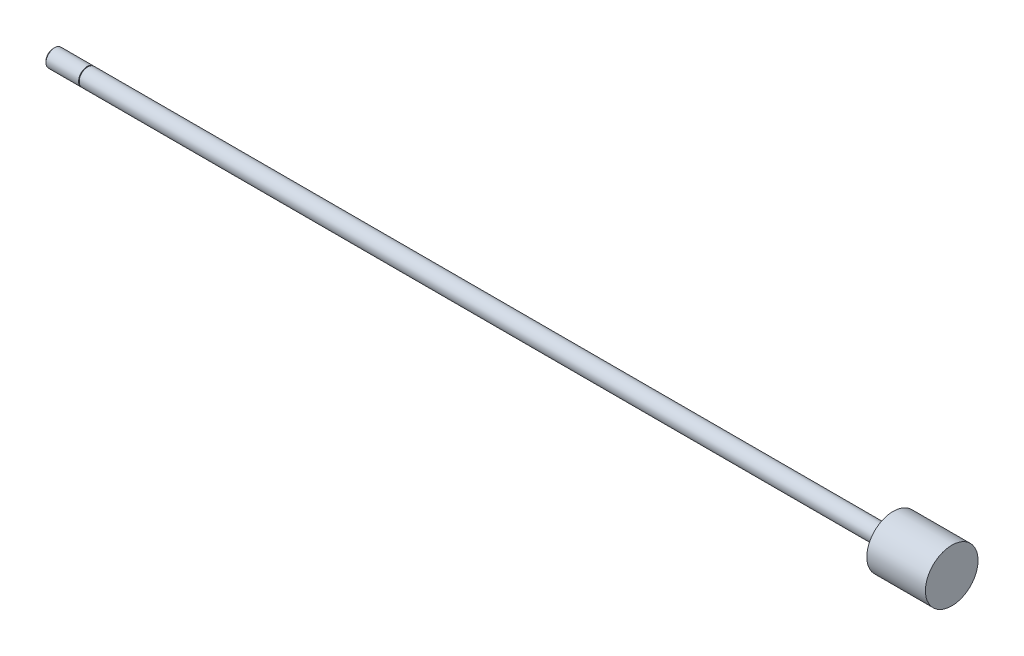
from build123d import *

# Parameters (mm, degrees)
SKETCH3_W = 0.254
SKETCH3_H = 0.508


with BuildPart() as part:
    # Sketch1 → Revolve1 (revolve)
    with BuildSketch(Plane.XY):
        Polygon((0, 0), (0, 3.175), (294.4876, 3.175), (294.4876, 9.62025), (315.9252, 9.62025), (315.9252, 0), align=None)
    revolve(axis=Axis((315.9252, 0, 0), (-1, 0, 0)))

    # Sketch2 → Revolve2 (revolve)
    with BuildSketch(Plane.XY):
        Polygon((-12.7, 0), (-12.7, 2.63398), (-12.15898, 3.175), (0, 3.175), (0, 0), align=None)
    revolve(axis=Axis((0, 0, 0), (-1, 0, 0)))

    # Sketch3 → Cut-Revolve1 (revolve, cut)
    with BuildSketch(Plane.XY):
        with Locations((-0.127, 3.175)):
            Rectangle(SKETCH3_W, SKETCH3_H)
    revolve(axis=Axis((0, 0, 0), (-1, 0, 0)), mode=Mode.SUBTRACT)


solid = part.part
